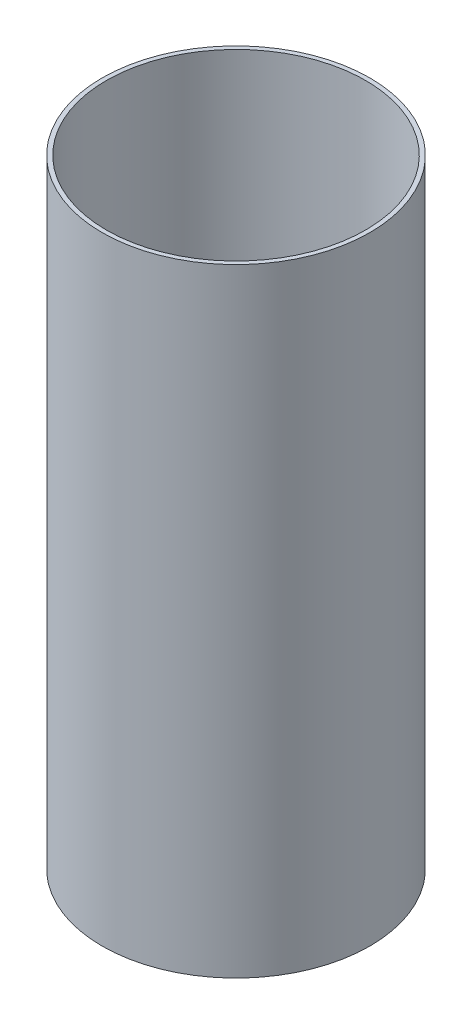
from build123d import *

# Parameters (mm, degrees)
SKETCH1_R           = 49.55
SKETCH1_R_2         = 47.95
BOSS_EXTRUDE1_DEPTH = 228.6


with BuildPart() as part:
    # Sketch1 → Boss-Extrude1 (new body)
    with BuildSketch(Plane(origin=(0, 0, 0), x_dir=(1, 0, 0), z_dir=(0, 1, 0))):
        Circle(SKETCH1_R)
        Circle(SKETCH1_R_2, mode=Mode.SUBTRACT)
    extrude(amount=BOSS_EXTRUDE1_DEPTH)


solid = part.part
